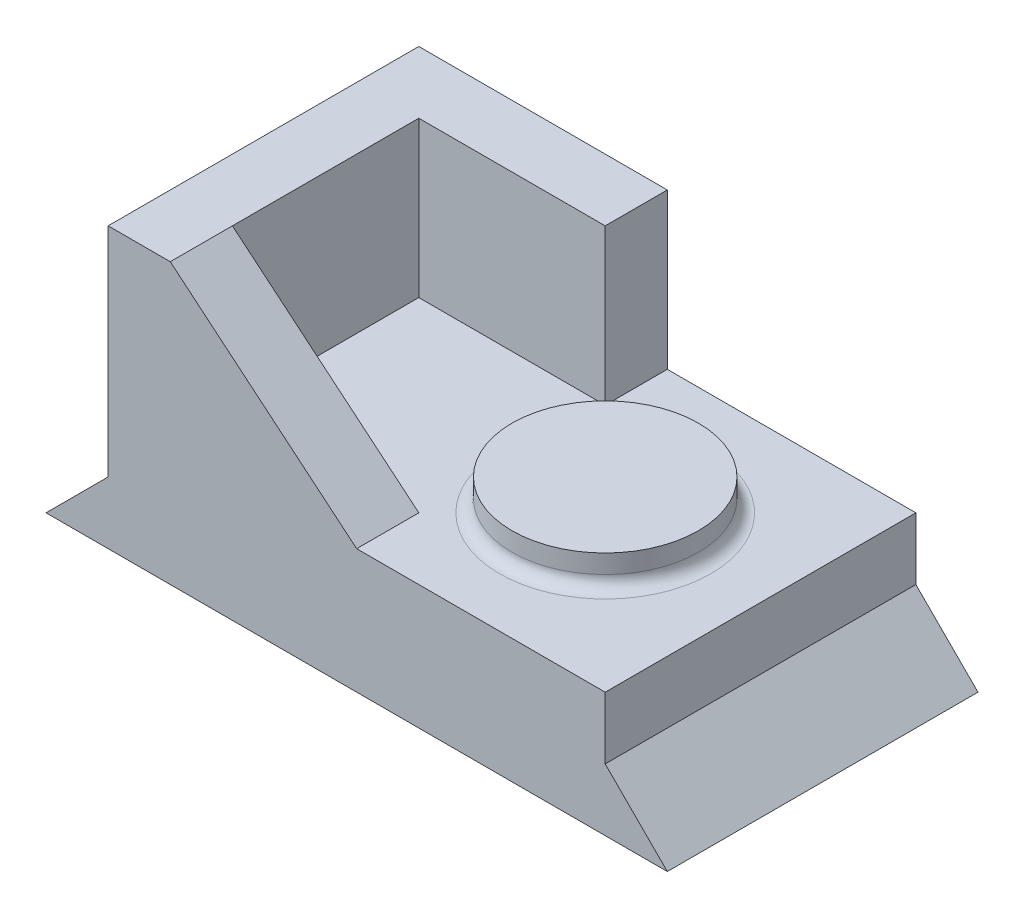
from build123d import *

# Parameters (mm, degrees)
BOSS_EXTRU_1_DEPTH = 25
BOSS_EXTRU_4_START = 15
BOSS_EXTRU_4_DEPTH = 10
BOSS_EXTRU_5_START = -15
BOSS_EXTRU_5_DEPTH = 10
ESQUISSE1_9_W      = 15
ESQUISSE1_9_H      = 5
CONG_1_R           = 2


with BuildPart() as part:
    # Esquisse1 → Boss.-Extru.1 (new body, symmetric)
    with BuildSketch(Plane.XY):
        Polygon((10, 10), (0, 0), (100, 0), (90, 10), (90, 20), (20, 20), (20, 45), (10, 45), align=None)
    extrude(amount=BOSS_EXTRU_1_DEPTH, both=True)

    # Esquisse1_5 → Boss.-Extru.4 (add)
    with BuildSketch(Plane.XY.offset(BOSS_EXTRU_4_START)):
        Polygon((20, 45), (20, 20), (50, 20), align=None)
    extrude(amount=BOSS_EXTRU_4_DEPTH)

    # Esquisse1_6 → Boss.-Extru.5 (add)
    with BuildSketch(Plane.XY.offset(BOSS_EXTRU_5_START)):
        Polygon((20, 45), (20, 20), (50, 20), align=None)
        Polygon((50, 45), (20, 45), (50, 20), align=None)
    extrude(amount=-BOSS_EXTRU_5_DEPTH)

    # Esquisse1_9 → R_volution1 (revolve)
    with BuildSketch(Plane.XY):
        with Locations((72.5, 22.5)):
            Rectangle(ESQUISSE1_9_W, ESQUISSE1_9_H)
    revolve(axis=Axis((65, 46.334519573, 0), (0, -1, 0)))

    # Cong_1
    cong_1_edges = [part.edges().sort_by_distance(p)[0] for p in [
        (50, 20, 0),
    ]]
    fillet(cong_1_edges, radius=CONG_1_R)


solid = part.part
